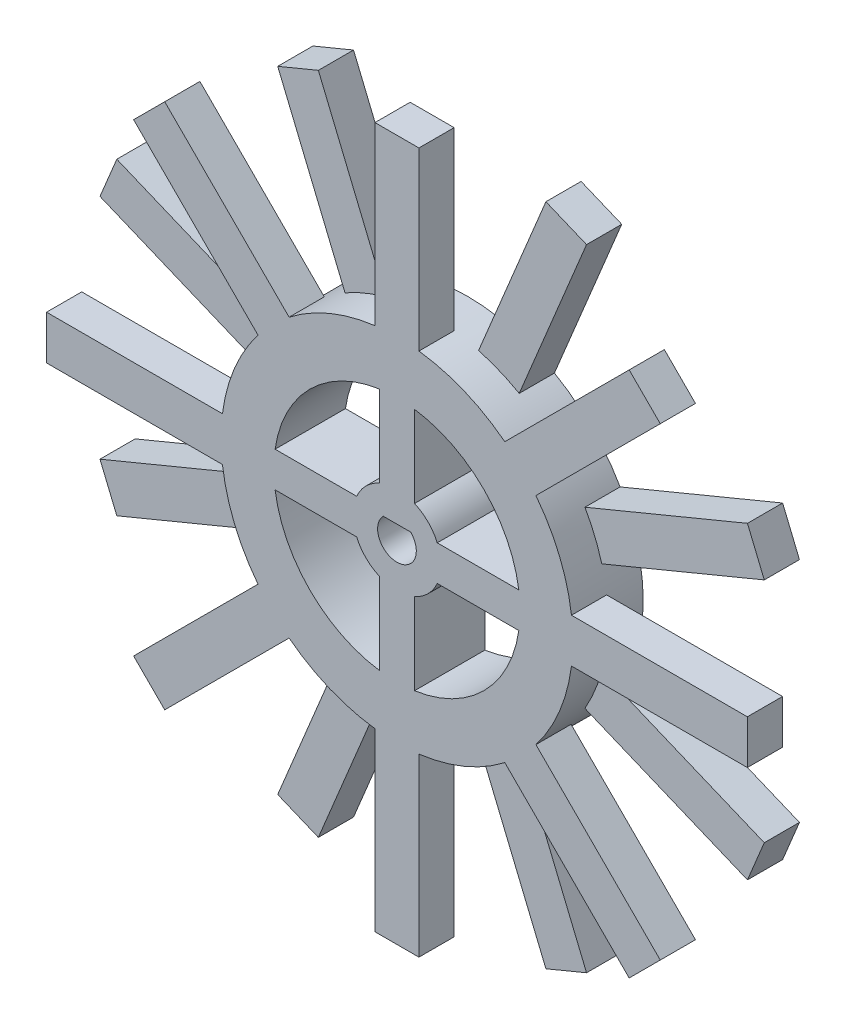
from build123d import *

# Parameters (mm, degrees)
SKETCH_2_R               = 20
EXTRUDE_3_DEPTH          = 4
CUT_EXTRUDE_6_DEPTH      = 29.565713714
CUT_EXTRUDE_6_DEPTH_BACK = 29.565713714
CUT_EXTRUDE_7_DEPTH      = 29.565713714
CUT_EXTRUDE_7_DEPTH_BACK = 29.565713714
EXTRUDE_START            = 4
EXTRUDE_4_DEPTH          = 4
EXTRUDE_5_DEPTH          = 4


with BuildPart() as part:
    # Эскиз2 → Бобышка-Вытянуть3 (new, symmetric)
    with BuildSketch(Plane.XY):
        Circle(SKETCH_2_R)
    extrude(amount=EXTRUDE_3_DEPTH, both=True)

    # Эскиз2<10> → Вырез-Вытянуть6 (cut, two sides: drawn at the far end of the back side and taken through both)
    with BuildSketch(Plane.XY.offset(-CUT_EXTRUDE_6_DEPTH_BACK)):
        with BuildLine():
            Line((-1.5612495, 1.55), (1.5612495, 1.55))
            ThreePointArc((1.5612495, 1.55), (0, -2.2), (-1.5612495, 1.55))
        make_face()
    extrude(amount=CUT_EXTRUDE_6_DEPTH + CUT_EXTRUDE_6_DEPTH_BACK, mode=Mode.SUBTRACT)

    # Эскиз2<11> → Вырез-Вытянуть7 (cut, two sides: drawn at the far end of the back side and taken through both)
    with BuildSketch(Plane.XY.offset(-CUT_EXTRUDE_7_DEPTH_BACK)):
        with BuildLine():
            ThreePointArc((-2, 13.856406461), (-9.899494937, 9.899494937), (-13.856406461, 2))
            Line((-13.856406461, 2), (-4.582575695, 2))
            ThreePointArc((-4.582575695, 2), (-3.535533906, 3.535533906), (-2, 4.582575695))
            Line((-2, 4.582575695), (-2, 13.856406461))
        make_face()
        with BuildLine():
            Line((-4.582575695, -2), (-13.856406461, -2))
            ThreePointArc((-13.856406461, -2), (-9.899494937, -9.899494937), (-2, -13.856406461))
            Line((-2, -13.856406461), (-2, -4.582575695))
            ThreePointArc((-2, -4.582575695), (-3.535533906, -3.535533906), (-4.582575695, -2))
        make_face()
        with BuildLine():
            ThreePointArc((13.856406461, 2), (9.899494937, 9.899494937), (2, 13.856406461))
            Line((2, 13.856406461), (2, 4.582575695))
            ThreePointArc((2, 4.582575695), (3.535533906, 3.535533906), (4.582575695, 2))
            Line((4.582575695, 2), (13.856406461, 2))
        make_face()
        with BuildLine():
            Line((2, -4.582575695), (2, -13.856406461))
            ThreePointArc((2, -13.856406461), (9.899494937, -9.899494937), (13.856406461, -2))
            Line((13.856406461, -2), (4.582575695, -2))
            ThreePointArc((4.582575695, -2), (3.535533906, -3.535533906), (2, -4.582575695))
        make_face()
    extrude(amount=CUT_EXTRUDE_7_DEPTH + CUT_EXTRUDE_7_DEPTH_BACK, mode=Mode.SUBTRACT)

    # Эскиз2<12> → Бобышка-Вытянуть4 (add)
    with BuildSketch(Plane.XY.offset(EXTRUDE_START)):
        with BuildLine():
            Line((-39.843134833, -2.5), (-19.843134833, -2.5))
            ThreePointArc((-19.843134833, -2.5), (-20, 0), (-19.843134833, 2.5))
            Line((-19.843134833, 2.5), (-39.843134833, 2.5))
            Line((-39.843134833, 2.5), (-39.843134833, -2.5))
        make_face()
        with BuildLine():
            ThreePointArc((-12.263448247, -15.798982153), (-14.142135624, -14.142135624), (-15.798982153, -12.263448247))
            Line((-15.798982153, -12.263448247), (-29.941117777, -26.405583871))
            Line((-29.941117777, -26.405583871), (-26.405583871, -29.941117777))
            Line((-26.405583871, -29.941117777), (-12.263448247, -15.798982153))
        make_face()
        with BuildLine():
            Line((-29.941117777, 26.405583871), (-15.798982153, 12.263448247))
            ThreePointArc((-15.798982153, 12.263448247), (-14.142135624, 14.142135624), (-12.263448247, 15.798982153))
            Line((-12.263448247, 15.798982153), (-26.405583871, 29.941117777))
            Line((-26.405583871, 29.941117777), (-29.941117777, 26.405583871))
        make_face()
        with BuildLine():
            ThreePointArc((2.5, -19.843134833), (0, -20), (-2.5, -19.843134833))
            Line((-2.5, -19.843134833), (-2.5, -39.843134833))
            Line((-2.5, -39.843134833), (2.5, -39.843134833))
            Line((2.5, -39.843134833), (2.5, -19.843134833))
        make_face()
        with BuildLine():
            Line((-2.5, 39.843134833), (-2.5, 19.843134833))
            ThreePointArc((-2.5, 19.843134833), (0, 20), (2.5, 19.843134833))
            Line((2.5, 19.843134833), (2.5, 39.843134833))
            Line((2.5, 39.843134833), (-2.5, 39.843134833))
        make_face()
        with BuildLine():
            ThreePointArc((15.798982153, -12.263448247), (14.142135624, -14.142135624), (12.263448247, -15.798982153))
            Line((12.263448247, -15.798982153), (26.405583871, -29.941117777))
            Line((26.405583871, -29.941117777), (29.941117777, -26.405583871))
            Line((29.941117777, -26.405583871), (15.798982153, -12.263448247))
        make_face()
        with BuildLine():
            Line((26.405583871, 29.941117777), (12.263448247, 15.798982153))
            ThreePointArc((12.263448247, 15.798982153), (14.142135624, 14.142135624), (15.798982153, 12.263448247))
            Line((15.798982153, 12.263448247), (29.941117777, 26.405583871))
            Line((29.941117777, 26.405583871), (26.405583871, 29.941117777))
        make_face()
        with BuildLine():
            ThreePointArc((19.843134833, 2.5), (20, 0), (19.843134833, -2.5))
            Line((19.843134833, -2.5), (39.843134833, -2.5))
            Line((39.843134833, -2.5), (39.843134833, 2.5))
            Line((39.843134833, 2.5), (19.843134833, 2.5))
        make_face()
    extrude(amount=-EXTRUDE_4_DEPTH)

    # Эскиз2<13> → Бобышка-Вытянуть5 (add)
    with BuildSketch(Plane.XY):
        with BuildLine():
            ThreePointArc((-17.375957552, -9.903337778), (-18.47759065, -7.653668647), (-19.289374714, -5.283940115))
            Line((-19.289374714, -5.283940115), (-37.766965364, -12.937608763))
            Line((-37.766965364, -12.937608763), (-35.853548202, -17.557006425))
            Line((-35.853548202, -17.557006425), (-17.375957552, -9.903337778))
        make_face()
        with BuildLine():
            Line((-37.766965364, 12.937608763), (-19.289374714, 5.283940115))
            ThreePointArc((-19.289374714, 5.283940115), (-18.47759065, 7.653668647), (-17.375957552, 9.903337778))
            Line((-17.375957552, 9.903337778), (-35.853548202, 17.557006425))
            Line((-35.853548202, 17.557006425), (-37.766965364, 12.937608763))
        make_face()
        with BuildLine():
            ThreePointArc((-5.283940115, -19.289374714), (-7.653668647, -18.47759065), (-9.903337778, -17.375957552))
            Line((-9.903337778, -17.375957552), (-17.557006425, -35.853548202))
            Line((-17.557006425, -35.853548202), (-12.937608763, -37.766965364))
            Line((-12.937608763, -37.766965364), (-5.283940115, -19.289374714))
        make_face()
        with BuildLine():
            Line((-17.557006425, 35.853548202), (-9.903337778, 17.375957552))
            ThreePointArc((-9.903337778, 17.375957552), (-7.653668647, 18.47759065), (-5.283940115, 19.289374714))
            Line((-5.283940115, 19.289374714), (-12.937608763, 37.766965364))
            Line((-12.937608763, 37.766965364), (-17.557006425, 35.853548202))
        make_face()
        with BuildLine():
            ThreePointArc((9.903337778, -17.375957552), (7.653668647, -18.47759065), (5.283940115, -19.289374714))
            Line((5.283940115, -19.289374714), (12.937608763, -37.766965364))
            Line((12.937608763, -37.766965364), (17.557006425, -35.853548202))
            Line((17.557006425, -35.853548202), (9.903337778, -17.375957552))
        make_face()
        with BuildLine():
            Line((12.937608763, 37.766965364), (5.283940115, 19.289374714))
            ThreePointArc((5.283940115, 19.289374714), (7.653668647, 18.47759065), (9.903337778, 17.375957552))
            Line((9.903337778, 17.375957552), (17.557006425, 35.853548202))
            Line((17.557006425, 35.853548202), (12.937608763, 37.766965364))
        make_face()
        with BuildLine():
            ThreePointArc((19.289374714, -5.283940115), (18.47759065, -7.653668647), (17.375957552, -9.903337778))
            Line((17.375957552, -9.903337778), (35.853548202, -17.557006425))
            Line((35.853548202, -17.557006425), (37.766965364, -12.937608763))
            Line((37.766965364, -12.937608763), (19.289374714, -5.283940115))
        make_face()
        with BuildLine():
            Line((35.853548202, 17.557006425), (17.375957552, 9.903337778))
            ThreePointArc((17.375957552, 9.903337778), (18.47759065, 7.653668647), (19.289374714, 5.283940115))
            Line((19.289374714, 5.283940115), (37.766965364, 12.937608763))
            Line((37.766965364, 12.937608763), (35.853548202, 17.557006425))
        make_face()
    extrude(amount=-EXTRUDE_5_DEPTH)


solid = part.part
